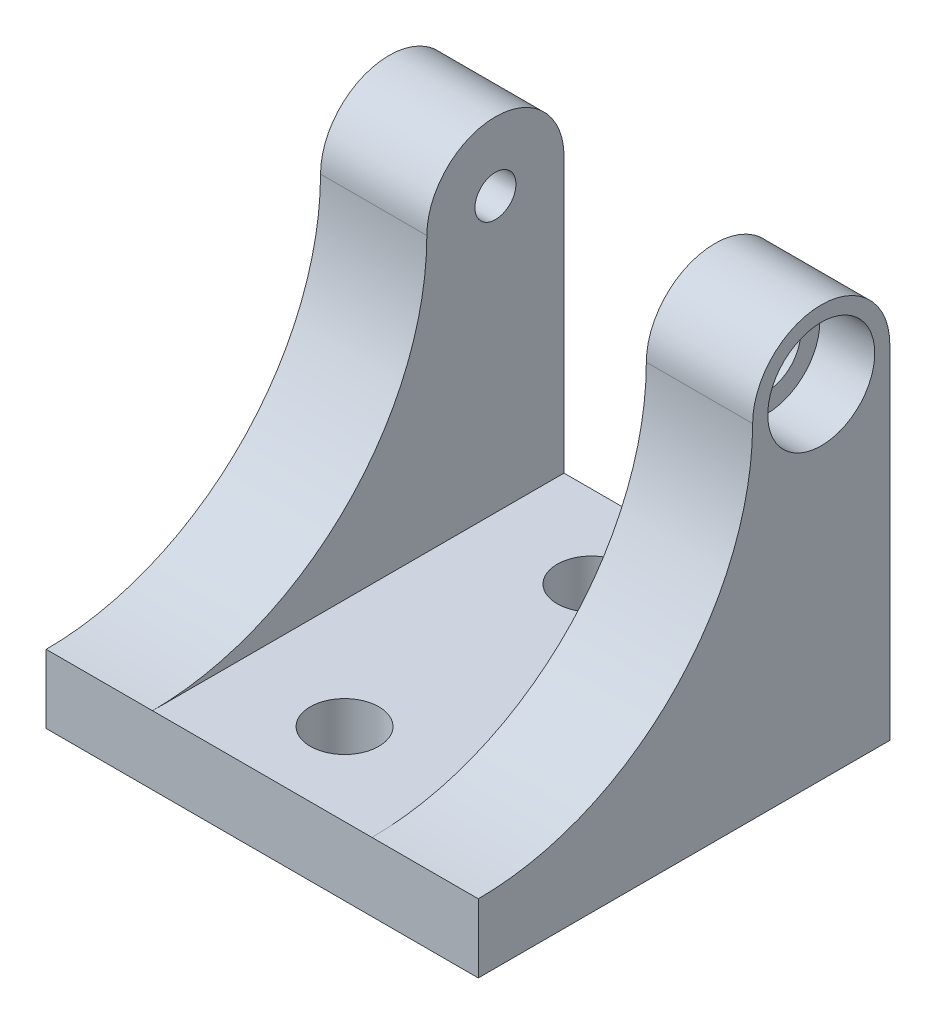
from build123d import *

# Parameters (mm, degrees)
EXTRUDE3_DEPTH                 = 40.005
SKETCH6_W                      = 20.32
SKETCH6_H                      = 42.20483691
EXTRUDE_SLOT_DEPTH             = 39.1
SKETCH8_R                      = 3.175
EXTRUDE_SHOULDER_THROUGH_DEPTH = 9.8425
SKETCH9_R                      = 4.953
EXTRUDE_CNTR_BORE_DEPTH        = 5.08
F_10_24_TAPPED_HOLE1_D         = 3.7973
F_10_24_TAPPED_HOLE1_DEPTH     = 12.827
F_10_24_TAPPED_HOLE1_TIP       = 1.140824014
SKETCH13_R                     = 3.175
EXTRUDE7_DEPTH                 = 39.1


with BuildPart() as part:
    # Sketch5 → Extrude3 (new body)
    with BuildSketch(Plane(origin=(0, 0, 0), x_dir=(0, 0, -1), z_dir=(1, 0, 0))):
        with BuildLine():
            Line((0, 0), (38.1, 0))
            Line((38.1, 0), (38.1, 31.75))
            ThreePointArc((38.1, 31.75), (31.75, 38.1), (25.4, 31.75))
            ThreePointArc((25.4, 31.75), (17.960512242, 13.789487758), (0, 6.35))
            Line((0, 6.35), (0, 0))
        make_face()
    extrude(amount=EXTRUDE3_DEPTH)

    # Sketch6 → Extrude - Slot (cut, through all)
    with BuildSketch(Plane(origin=(0, 0, -38.1), x_dir=(-1, 0, 0), z_dir=(0, 0, -1))):
        with Locations((-20.0025, 27.452418455)):
            Rectangle(SKETCH6_W, SKETCH6_H)
    extrude(amount=-EXTRUDE_SLOT_DEPTH, mode=Mode.SUBTRACT)

    # Sketch8 → Extrude - shoulder through (cut)
    with BuildSketch(Plane(origin=(40.005, 0, 0), x_dir=(0, 0, -1), z_dir=(1, 0, 0))):
        with Locations((31.75, 31.75)):
            Circle(SKETCH8_R)
    extrude(amount=-EXTRUDE_SHOULDER_THROUGH_DEPTH, mode=Mode.SUBTRACT)

    # Sketch9 → Extrude - cntr bore (cut)
    with BuildSketch(Plane(origin=(40.005, 0, 0), x_dir=(0, 0, -1), z_dir=(1, 0, 0))):
        with Locations((31.75, 31.75)):
            Circle(SKETCH9_R)
    extrude(amount=-EXTRUDE_CNTR_BORE_DEPTH, mode=Mode.SUBTRACT)

    # #10-24 Tapped Hole1
    with Locations(Plane(origin=(0, 31.75, -31.75), x_dir=(0, 0, -1), z_dir=(-1, 0, 0))):
        with Locations((0, 0)):
            Hole(F_10_24_TAPPED_HOLE1_D / 2, depth=F_10_24_TAPPED_HOLE1_DEPTH)
            with Locations((0, 0, -(F_10_24_TAPPED_HOLE1_DEPTH + F_10_24_TAPPED_HOLE1_TIP / 2))):  # 118° drill point
                Cone(0, F_10_24_TAPPED_HOLE1_D / 2, F_10_24_TAPPED_HOLE1_TIP, mode=Mode.SUBTRACT)

    # Sketch13 → Extrude7 (cut, through all)
    with BuildSketch(Plane.XZ):
        with Locations((20.0025, -7.62)):
            Circle(SKETCH13_R)
        with Locations((20.0025, -30.48)):
            Circle(SKETCH13_R)
    extrude(amount=-EXTRUDE7_DEPTH, mode=Mode.SUBTRACT)


solid = part.part
